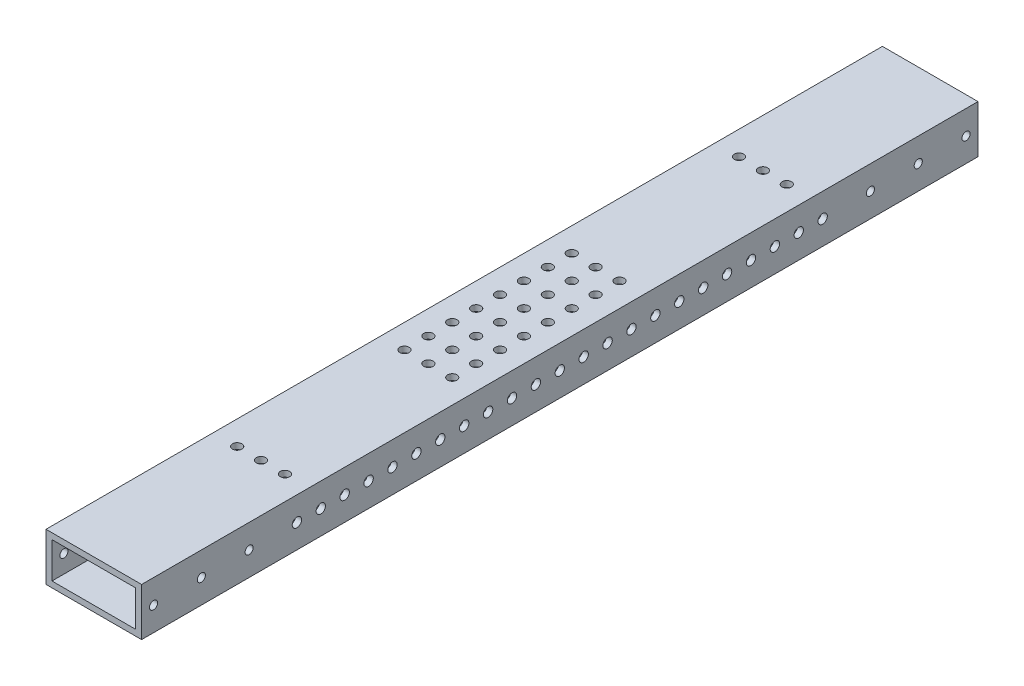
from build123d import *

# Parameters (mm, degrees)
SKETCH1_W           = 50.8
SKETCH1_H           = 25.4
SKETCH1_W_2         = 44.45
SKETCH1_H_2         = 19.05
BOSS_EXTRUDE1_DEPTH = 222.25
SKETCH3_R           = 2.15265
SKETCH3_R_2         = 2.159
CUT_EXTRUDE2_DEPTH  = 51.8
SKETCH4_R           = 2.4892
CUT_EXTRUDE3_DEPTH  = 51.8
SKETCH5_R           = 2.4892
CUT_EXTRUDE4_DEPTH  = 26.4


with BuildPart() as part:
    # Sketch1 → Boss-Extrude1 (new body, symmetric)
    with BuildSketch(Plane.XY):
        Rectangle(SKETCH1_W, SKETCH1_H)
        Rectangle(SKETCH1_W_2, SKETCH1_H_2, mode=Mode.SUBTRACT)
    extrude(amount=BOSS_EXTRUDE1_DEPTH, both=True)

    # Sketch3 → Cut-Extrude2 (cut, through all)
    with BuildSketch(Plane(origin=(25.4, 0, 0), x_dir=(0, 0, -1), z_dir=(1, 0, 0))):
        with Locations((-215.9, 0)):
            Circle(SKETCH3_R)
        with Locations((-190.5, 0)):
            Circle(SKETCH3_R)
        with Locations((-165.1, 0)):
            Circle(SKETCH3_R)
        with Locations((215.9, 0)):
            Circle(SKETCH3_R_2)
        with Locations((190.5, 0)):
            Circle(SKETCH3_R_2)
        with Locations((165.1, 0)):
            Circle(SKETCH3_R_2)
    extrude(amount=-CUT_EXTRUDE2_DEPTH, mode=Mode.SUBTRACT)

    # Sketch4 → Cut-Extrude3 (cut, through all)
    with BuildSketch(Plane(origin=(25.4, 0, 0), x_dir=(0, 0, -1), z_dir=(1, 0, 0))):
        with Locations((-139.7, 0)):
            Circle(SKETCH4_R)
        with Locations((-127, 0)):
            Circle(SKETCH4_R)
        with Locations((-114.3, 0)):
            Circle(SKETCH4_R)
        with Locations((-101.6, 0)):
            Circle(SKETCH4_R)
        with Locations((-88.9, 0)):
            Circle(SKETCH4_R)
        with Locations((-76.2, 0)):
            Circle(SKETCH4_R)
        with Locations((-63.5, 0)):
            Circle(SKETCH4_R)
        with Locations((-50.8, 0)):
            Circle(SKETCH4_R)
        with Locations((-38.1, 0)):
            Circle(SKETCH4_R)
        with Locations((-25.4, 0)):
            Circle(SKETCH4_R)
        with Locations((-12.7, 0)):
            Circle(SKETCH4_R)
        Circle(SKETCH4_R)
        with Locations((12.7, 0)):
            Circle(SKETCH4_R)
        with Locations((25.4, 0)):
            Circle(SKETCH4_R)
        with Locations((38.1, 0)):
            Circle(SKETCH4_R)
        with Locations((50.8, 0)):
            Circle(SKETCH4_R)
        with Locations((63.5, 0)):
            Circle(SKETCH4_R)
        with Locations((76.2, 0)):
            Circle(SKETCH4_R)
        with Locations((88.9, 0)):
            Circle(SKETCH4_R)
        with Locations((101.6, 0)):
            Circle(SKETCH4_R)
        with Locations((114.3, 0)):
            Circle(SKETCH4_R)
        with Locations((127, 0)):
            Circle(SKETCH4_R)
        with Locations((139.7, 0)):
            Circle(SKETCH4_R)
    extrude(amount=-CUT_EXTRUDE3_DEPTH, mode=Mode.SUBTRACT)

    # Sketch5 → Cut-Extrude4 (cut, through all)
    with BuildSketch(Plane.XZ.offset(12.7)):
        with Locations((-12.7, 133.35)):
            Circle(SKETCH5_R)
        with Locations((0, 133.35)):
            Circle(SKETCH5_R)
        with Locations((12.7, 133.35)):
            Circle(SKETCH5_R)
        with Locations((12.7, -133.35)):
            Circle(SKETCH5_R)
        with Locations((0, -133.35)):
            Circle(SKETCH5_R)
        with Locations((-12.7, -133.35)):
            Circle(SKETCH5_R)
        with Locations((-12.7, 44.45)):
            Circle(SKETCH5_R)
        with Locations((0, 44.45)):
            Circle(SKETCH5_R)
        with Locations((12.7, 44.45)):
            Circle(SKETCH5_R)
        with Locations((12.7, 31.75)):
            Circle(SKETCH5_R)
        with Locations((0, 31.75)):
            Circle(SKETCH5_R)
        with Locations((-12.7, 31.75)):
            Circle(SKETCH5_R)
        with Locations((12.7, 19.05)):
            Circle(SKETCH5_R)
        with Locations((0, 19.05)):
            Circle(SKETCH5_R)
        with Locations((-12.7, 19.05)):
            Circle(SKETCH5_R)
        with Locations((12.7, 6.35)):
            Circle(SKETCH5_R)
        with Locations((0, 6.35)):
            Circle(SKETCH5_R)
        with Locations((-12.7, 6.35)):
            Circle(SKETCH5_R)
        with Locations((12.7, -6.35)):
            Circle(SKETCH5_R)
        with Locations((0, -6.35)):
            Circle(SKETCH5_R)
        with Locations((-12.7, -6.35)):
            Circle(SKETCH5_R)
        with Locations((12.7, -19.05)):
            Circle(SKETCH5_R)
        with Locations((0, -19.05)):
            Circle(SKETCH5_R)
        with Locations((-12.7, -19.05)):
            Circle(SKETCH5_R)
        with Locations((12.7, -31.75)):
            Circle(SKETCH5_R)
        with Locations((0, -31.75)):
            Circle(SKETCH5_R)
        with Locations((-12.7, -31.75)):
            Circle(SKETCH5_R)
        with Locations((12.7, -44.45)):
            Circle(SKETCH5_R)
        with Locations((0, -44.45)):
            Circle(SKETCH5_R)
        with Locations((-12.7, -44.45)):
            Circle(SKETCH5_R)
    extrude(amount=-CUT_EXTRUDE4_DEPTH, mode=Mode.SUBTRACT)


solid = part.part
